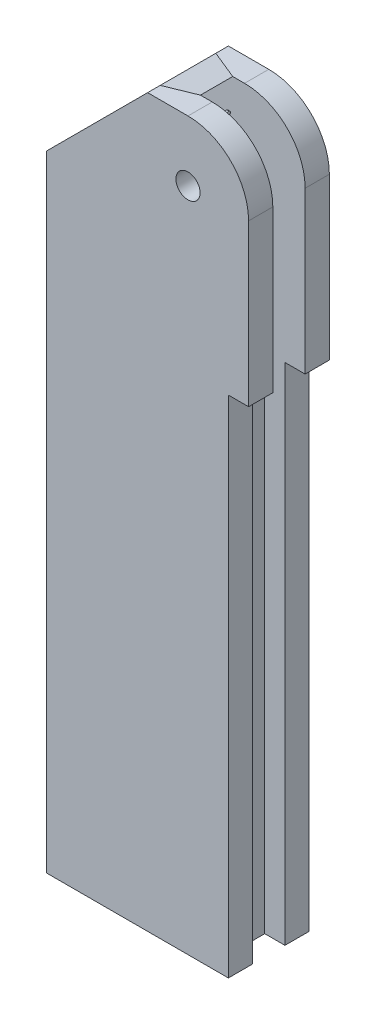
from build123d import *

# Parameters (mm, degrees)
ESQUISSE1_R             = 3
EXTRUSION1_DEPTH        = 10
EXTRUSION1_DEPTH_BACK   = 10
ESQUISSE2_W             = 8
ESQUISSE2_H             = 38.994969405
ENL_V_MAT_EXTRU_2_DEPTH = 51
CHANFREIN1_SIZE         = 5
CHANFREIN1_SIZE2        = 2.886751346
CHANFREIN1_PART_2_SIZE  = 5
CHANFREIN1_PART_2_SIZE2 = 2.886751346
ESQUISSE3_W             = 10.585305106
ESQUISSE3_H             = 8
ENL_V_MAT_EXTRU_3_DEPTH = 150.85
ESQUISSE4_R             = 0.5
EXTRUSION2_DEPTH        = 0.5


with BuildPart() as part:
    # Esquisse1 → Extrusion1 (new body, two sides)
    with BuildSketch(Plane.XY) as extrusion1_sk:
        with BuildLine():
            Line((-35, -10), (-10, 15))
            Line((-10, 15), (0, 15))
            ThreePointArc((0, 15), (10.606601718, 10.606601718), (15, 0))
            Line((15, 0), (15, -39.85))
            Line((15, -39.85), (10, -39.85))
            Line((10, -39.85), (10, -164.85))
            Line((10, -164.85), (-35, -164.85))
            Line((-35, -164.85), (-35, -10))
        make_face()
        Circle(ESQUISSE1_R, mode=Mode.SUBTRACT)
    extrude(amount=EXTRUSION1_DEPTH)
    extrude(extrusion1_sk.sketch, amount=-EXTRUSION1_DEPTH_BACK)

    # Esquisse2 → Enl_v. mat.-Extru.2 (cut, through all)
    with BuildSketch(Plane(origin=(15, 0, 0), x_dir=(0, 0, -1), z_dir=(1, 0, 0))):
        with Locations((0, 4.497484703)):
            Rectangle(ESQUISSE2_W, ESQUISSE2_H)
    extrude(amount=-ENL_V_MAT_EXTRU_2_DEPTH, mode=Mode.SUBTRACT)

    # Chanfrein1
    chanfrein1_edges = [part.edges().sort_by_distance(p)[0] for p in [
        (-22.5, 2.5, 4),
    ]]
    chanfrein1_side = [part.faces().sort_by_distance(p)[0] for p in [
        (-6.507250636, -2.381616227, 4),
    ]]
    chamfer(chanfrein1_edges, length=CHANFREIN1_SIZE, length2=CHANFREIN1_SIZE2, reference=chanfrein1_side[0])

    # Chanfrein1 part 2
    chanfrein1_part_2_edges = [part.edges().sort_by_distance(p)[0] for p in [
        (-22.5, 2.5, -4),
    ]]
    chanfrein1_part_2_side = [part.faces().sort_by_distance(p)[0] for p in [
        (-6.507250636, -2.381616227, -4),
    ]]
    chamfer(chanfrein1_part_2_edges, length=CHANFREIN1_PART_2_SIZE, length2=CHANFREIN1_PART_2_SIZE2, reference=chanfrein1_part_2_side[0])

    # Esquisse3 → Enl_v. mat.-Extru.3 (cut, through all)
    with BuildSketch(Plane(origin=(0, -15, 0), x_dir=(-1, 0, 0), z_dir=(0, 1, 0))):
        with Locations((-10.292652553, 0)):
            Rectangle(ESQUISSE3_W, ESQUISSE3_H)
    extrude(amount=-ENL_V_MAT_EXTRU_3_DEPTH, mode=Mode.SUBTRACT)


with BuildPart() as body_2:
    # Esquisse4 → Extrusion2 (new body)
    with BuildSketch(Plane(origin=(0, 0, 0), x_dir=(0, 0, -1), z_dir=(1, 0, 0))):
        with Locations((0, 10.5)):
            Circle(ESQUISSE4_R)
    extrude(amount=-EXTRUSION2_DEPTH)


solid = Compound([part.part, body_2.part])
